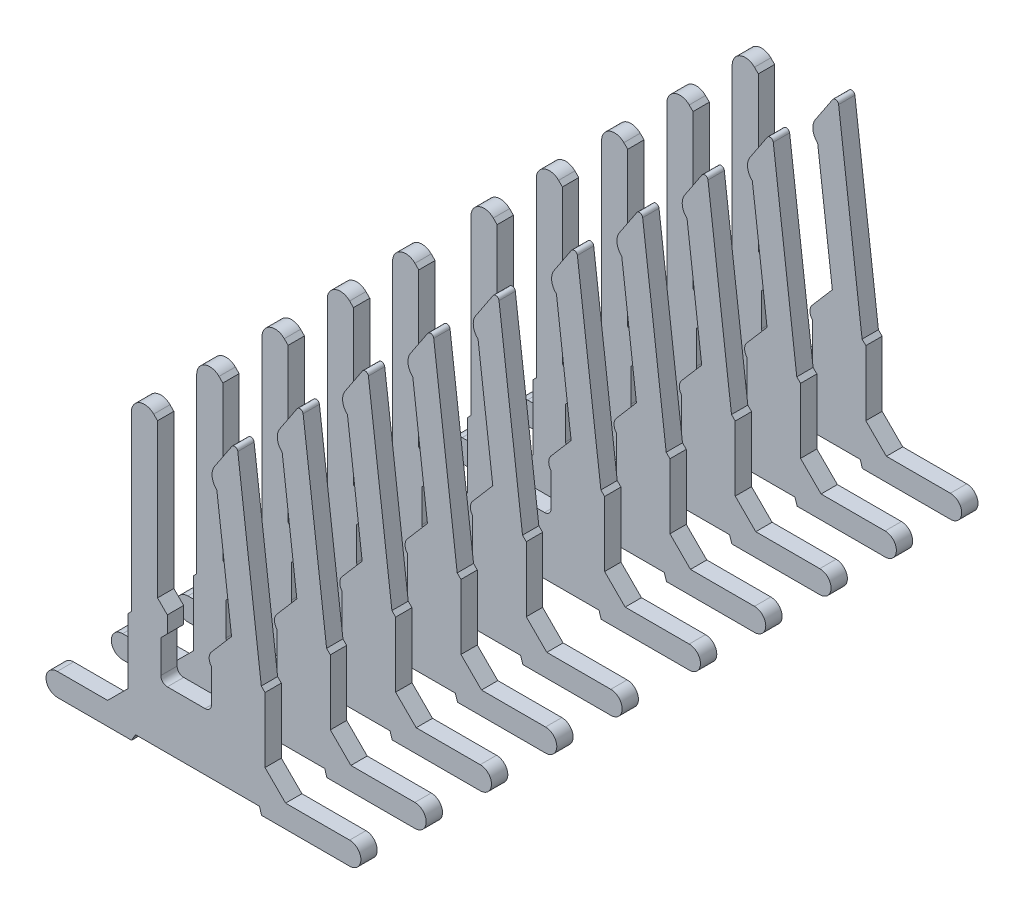
from build123d import *

# Parameters (mm, degrees)
BOSS_EXTRUDE1_DEPTH = 0.25
LPATTERN1_COUNT     = 5
LPATTERN1_PITCH     = 1
SZYK_LINIOWY1_COUNT = 2
SZYK_LINIOWY1_PITCH = 5.2


with BuildPart() as part:
    # Sketch1 → Boss-Extrude1 (new body)
    with BuildSketch(Plane.XY):
        with BuildLine():
            Line((1.154322642, 1.455960262), (1.096896052, 1.513386852))
            Line((1.096896052, 1.513386852), (0.737090693, 4.443766345))
            ThreePointArc((0.737090693, 4.443766345), (0.698972986, 4.486330139), (0.645825415, 4.465354631))
            Line((0.645825415, 4.465354631), (0.380448166, 4.066183018))
            ThreePointArc((0.380448166, 4.066183018), (0.344114023, 3.912579084), (0.416529041, 3.772327869))
            Line((0.416529041, 3.772327869), (0.641397744, 1.940919256))
            Line((0.641397744, 1.940919256), (0.334482222, 1.583614618))
            ThreePointArc((0.334482222, 1.583614618), (0.298267676, 1.485875831), (0.334482222, 1.388137044))
            Line((0.334482222, 1.388137044), (0.334482222, 0.883200693))
            ThreePointArc((0.334482222, 0.883200693), (0.3051929, 0.812490014), (0.234482222, 0.783200693))
            Line((0.234482222, 0.783200693), (-0.342129009, 0.783200693))
            ThreePointArc((-0.342129009, 0.783200693), (-0.412839687, 0.812490014), (-0.442129009, 0.883200693))
            Line((-0.442129009, 0.883200693), (-0.442129009, 1.384895673))
            Line((-0.442129009, 1.384895673), (-0.342129009, 1.484895673))
            Line((-0.342129009, 1.484895673), (-0.342129009, 1.7373543))
            Line((-0.342129009, 1.7373543), (-0.492129009, 1.8873543))
            Line((-0.492129009, 1.8873543), (-0.492129009, 4.236890131))
            Line((-0.492129009, 4.236890131), (-0.550707653, 4.295468774))
            ThreePointArc((-0.550707653, 4.295468774), (-0.768665696, 4.338823325), (-0.892129009, 4.154047418))
            Line((-0.892129009, 4.154047418), (-0.892129009, 1.505960262))
            Line((-0.892129009, 1.505960262), (-0.942129009, 1.455960262))
            Line((-0.942129009, 1.455960262), (-0.942129009, 0.46038227))
            Line((-0.942129009, 0.46038227), (-1.256596757, 0.145914522))
            Line((-1.256596757, 0.145914522), (-2.027042739, 0.145914522))
            ThreePointArc((-2.027042739, 0.145914522), (-2.2, -0.027042739), (-2.027042739, -0.2))
            Line((-2.027042739, -0.2), (-0.889717718, -0.2))
            Line((-0.889717718, -0.2), (-0.829198372, -0.095177417))
            Line((-0.829198372, -0.095177417), (1.068090373, -0.095177417))
            Line((1.068090373, -0.095177417), (1.101911351, -0.2))
            Line((1.101911351, -0.2), (2.448881537, -0.2))
            ThreePointArc((2.448881537, -0.2), (2.621838798, -0.027042739), (2.448881537, 0.145914522))
            Line((2.448881537, 0.145914522), (1.46879039, 0.145914522))
            Line((1.46879039, 0.145914522), (1.154322642, 0.46038227))
            Line((1.154322642, 0.46038227), (1.154322642, 1.455960262))
        make_face()
    extrude(amount=BOSS_EXTRUDE1_DEPTH)


with BuildPart() as lpattern1_1:
    # LPattern1: pattern copy
    add(part.part.moved(Location(Vector(0, 0, -1) * (1 * LPATTERN1_PITCH))))


with BuildPart() as lpattern1_2:
    # LPattern1: pattern copy
    add(part.part.moved(Location(Vector(0, 0, -1) * (2 * LPATTERN1_PITCH))))


with BuildPart() as lpattern1_3:
    # LPattern1: pattern copy
    add(part.part.moved(Location(Vector(0, 0, -1) * (3 * LPATTERN1_PITCH))))


with BuildPart() as lpattern1_4:
    # LPattern1: pattern copy
    add(part.part.moved(Location(Vector(0, 0, -1) * (4 * LPATTERN1_PITCH))))


with BuildPart() as szyk_liniowy1_1:
    # Szyk liniowy1: pattern copy
    add(part.part.moved(Location(Vector(0, 0, -1) * (1 * SZYK_LINIOWY1_PITCH))))


with BuildPart() as szyk_liniowy1_2:
    # Szyk liniowy1: pattern copy
    add(lpattern1_1.part.moved(Location(Vector(0, 0, -1) * (1 * SZYK_LINIOWY1_PITCH))))


with BuildPart() as szyk_liniowy1_3:
    # Szyk liniowy1: pattern copy
    add(lpattern1_2.part.moved(Location(Vector(0, 0, -1) * (1 * SZYK_LINIOWY1_PITCH))))


with BuildPart() as szyk_liniowy1_4:
    # Szyk liniowy1: pattern copy
    add(lpattern1_3.part.moved(Location(Vector(0, 0, -1) * (1 * SZYK_LINIOWY1_PITCH))))


with BuildPart() as szyk_liniowy1_5:
    # Szyk liniowy1: pattern copy
    add(lpattern1_4.part.moved(Location(Vector(0, 0, -1) * (1 * SZYK_LINIOWY1_PITCH))))


solid = Compound([part.part, lpattern1_1.part, lpattern1_2.part, lpattern1_3.part, lpattern1_4.part, szyk_liniowy1_1.part, szyk_liniowy1_2.part, szyk_liniowy1_3.part, szyk_liniowy1_4.part, szyk_liniowy1_5.part])
